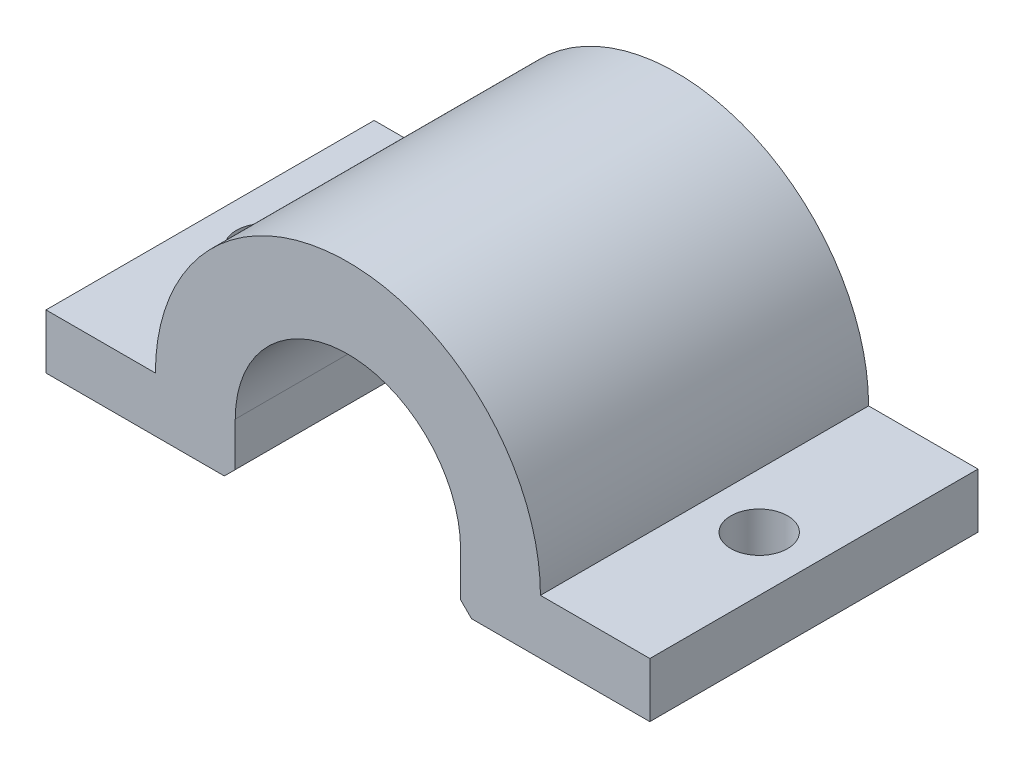
from build123d import *

# Parameters (mm, degrees)
BOSS_EXTRU_1_DEPTH      = 30
ESQUISSE3_R             = 2.6
ENL_V_MAT_EXTRU_1_DEPTH = 6
CHANFREIN1_SIZE         = 1


with BuildPart() as part:
    # Esquisse1 → Boss.-Extru.1 (new body)
    with BuildSketch(Plane.XY):
        with BuildLine():
            Line((-27.6, 0), (-17.6, 0))
            ThreePointArc((-17.6, 0), (0, 17.6), (17.6, 0))
            Line((17.6, 0), (27.6, 0))
            Line((27.6, 0), (27.6, -5))
            Line((27.6, -5), (10.3, -5))
            Line((10.3, -5), (10.3, 0))
            ThreePointArc((10.3, 0), (0, 10.3), (-10.3, 0))
            Line((-10.3, 0), (-10.3, -5))
            Line((-10.3, -5), (-27.6, -5))
            Line((-27.6, -5), (-27.6, 0))
        make_face()
    extrude(amount=BOSS_EXTRU_1_DEPTH)

    # Esquisse3 → Enlèv. mat.-Extru.1 (cut, through all)
    with BuildSketch(Plane(origin=(0, 0, 0), x_dir=(1, 0, 0), z_dir=(0, 1, 0))):
        with Locations((-22.6, -15)):
            Circle(ESQUISSE3_R)
        with Locations((22.6, -15)):
            Circle(ESQUISSE3_R)
    extrude(amount=-ENL_V_MAT_EXTRU_1_DEPTH, mode=Mode.SUBTRACT)

    # Chanfrein1
    chanfrein1_edges = [part.edges().sort_by_distance(p)[0] for p in [
        (-10.3, -5, 15),
        (10.3, -5, 15),
    ]]
    chamfer(chanfrein1_edges, length=CHANFREIN1_SIZE)


solid = part.part
